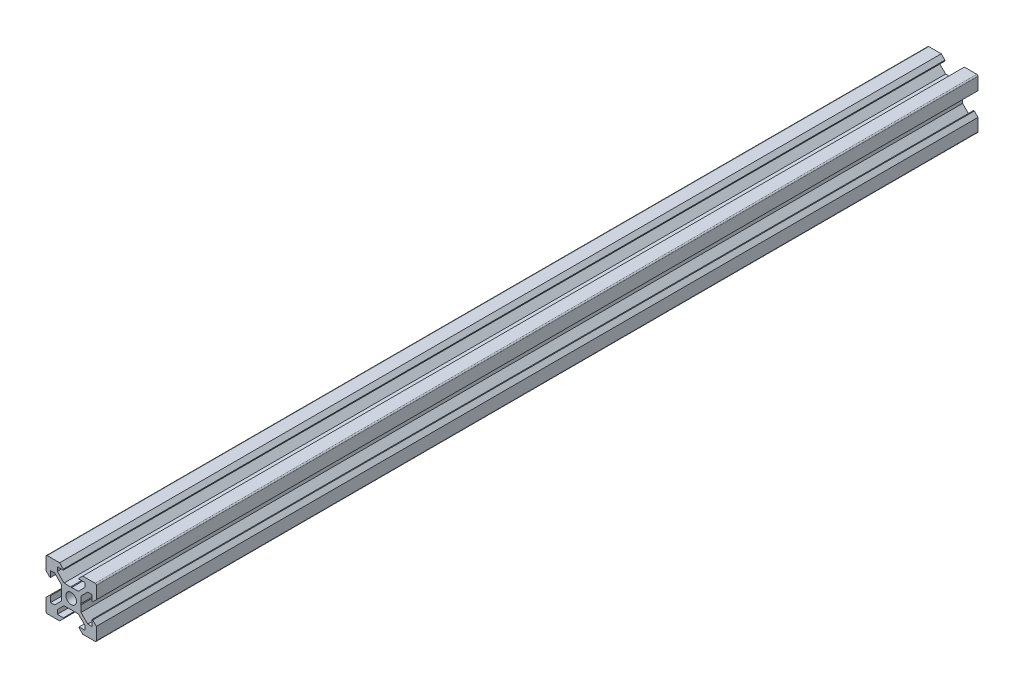
from build123d import *

# Parameters (mm, degrees)
SKETCH1_R           = 2.1
BOSS_EXTRUDE1_DEPTH = 350


with BuildPart() as part:
    # Sketch1 → Boss-Extrude1 (new body)
    with BuildSketch(Plane.XY):
        with BuildLine():
            Line((4.58, -10), (9.5, -10))
            ThreePointArc((9.5, -10), (9.853553391, -9.853553391), (10, -9.5))
            Line((10, -9.5), (10, -4.58))
            Line((10, -4.58), (8.545, -3.125))
            Line((8.545, -3.125), (8.2, -3.125))
            Line((8.2, -3.125), (8.2, -5.5))
            Line((8.2, -5.5), (6.560660172, -5.5))
            Line((6.560660172, -5.5), (3.9, -2.839339828))
            Line((3.9, -2.839339828), (3.9, -0.21))
            Line((3.9, -0.21), (3.69, 0))
            Line((3.69, 0), (3.9, 0.21))
            Line((3.9, 0.21), (3.9, 2.839339828))
            Line((3.9, 2.839339828), (6.560660172, 5.5))
            Line((6.560660172, 5.5), (8.2, 5.5))
            Line((8.2, 5.5), (8.2, 3.125))
            Line((8.2, 3.125), (8.545, 3.125))
            Line((8.545, 3.125), (10, 4.58))
            Line((10, 4.58), (10, 9.5))
            ThreePointArc((10, 9.5), (9.853553391, 9.853553391), (9.5, 10))
            Line((9.5, 10), (4.58, 10))
            Line((4.58, 10), (3.125, 8.545))
            Line((3.125, 8.545), (3.125, 8.2))
            Line((3.125, 8.2), (5.5, 8.2))
            Line((5.5, 8.2), (5.5, 6.560660172))
            Line((5.5, 6.560660172), (2.839339828, 3.9))
            Line((2.839339828, 3.9), (0.21, 3.9))
            Line((0.21, 3.9), (0, 3.69))
            Line((0, 3.69), (-0.21, 3.9))
            Line((-0.21, 3.9), (-2.839339828, 3.9))
            Line((-2.839339828, 3.9), (-5.5, 6.560660172))
            Line((-5.5, 6.560660172), (-5.5, 8.2))
            Line((-5.5, 8.2), (-3.125, 8.2))
            Line((-3.125, 8.2), (-3.125, 8.545))
            Line((-3.125, 8.545), (-4.58, 10))
            Line((-4.58, 10), (-9.5, 10))
            ThreePointArc((-9.5, 10), (-9.853553391, 9.853553391), (-10, 9.5))
            Line((-10, 9.5), (-10, 4.58))
            Line((-10, 4.58), (-8.545, 3.125))
            Line((-8.545, 3.125), (-8.2, 3.125))
            Line((-8.2, 3.125), (-8.2, 5.5))
            Line((-8.2, 5.5), (-6.560660172, 5.5))
            Line((-6.560660172, 5.5), (-3.9, 2.839339828))
            Line((-3.9, 2.839339828), (-3.9, 0.21))
            Line((-3.9, 0.21), (-3.69, 0))
            Line((-3.69, 0), (-3.9, -0.21))
            Line((-3.9, -0.21), (-3.9, -2.839339828))
            Line((-3.9, -2.839339828), (-6.560660172, -5.5))
            Line((-6.560660172, -5.5), (-8.2, -5.5))
            Line((-8.2, -5.5), (-8.2, -3.125))
            Line((-8.2, -3.125), (-8.545, -3.125))
            Line((-8.545, -3.125), (-10, -4.58))
            Line((-10, -4.58), (-10, -9.5))
            ThreePointArc((-10, -9.5), (-9.853553391, -9.853553391), (-9.5, -10))
            Line((-9.5, -10), (-4.58, -10))
            Line((-4.58, -10), (-3.125, -8.545))
            Line((-3.125, -8.545), (-3.125, -8.2))
            Line((-3.125, -8.2), (-5.5, -8.2))
            Line((-5.5, -8.2), (-5.5, -6.560660172))
            Line((-5.5, -6.560660172), (-2.839339828, -3.9))
            Line((-2.839339828, -3.9), (-0.21, -3.9))
            Line((-0.21, -3.9), (0, -3.69))
            Line((0, -3.69), (0.21, -3.9))
            Line((0.21, -3.9), (2.839339828, -3.9))
            Line((2.839339828, -3.9), (5.5, -6.560660172))
            Line((5.5, -6.560660172), (5.5, -8.2))
            Line((5.5, -8.2), (3.125, -8.2))
            Line((3.125, -8.2), (3.125, -8.545))
            Line((3.125, -8.545), (4.58, -10))
        make_face()
        Circle(SKETCH1_R, mode=Mode.SUBTRACT)
    extrude(amount=BOSS_EXTRUDE1_DEPTH)


solid = part.part
